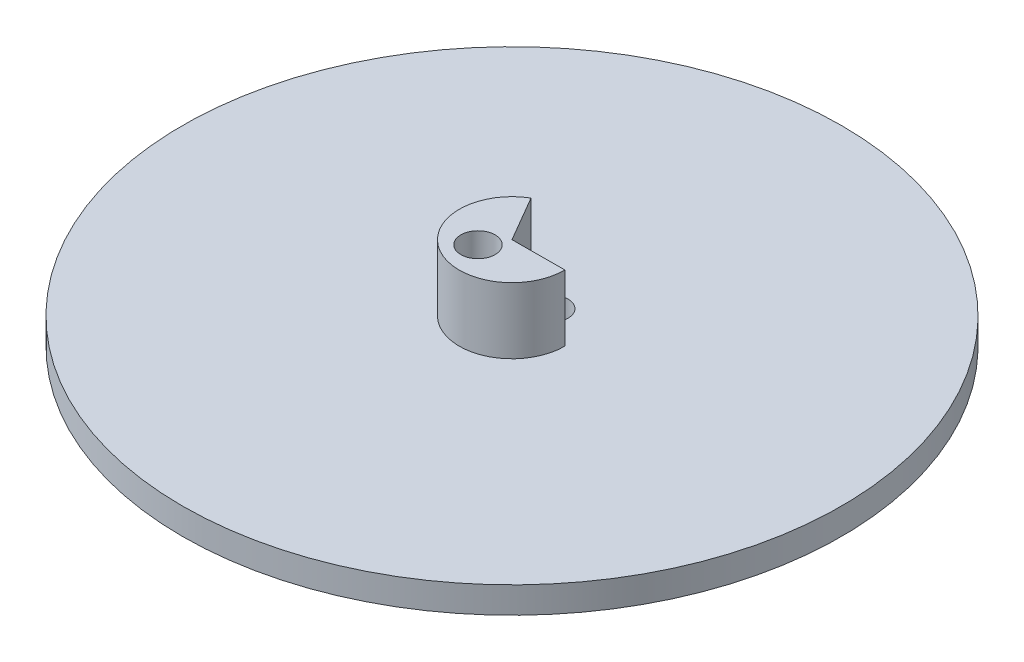
from build123d import *

# Parameters (mm, degrees)
SKETCH1_R           = 63.5
BOSS_EXTRUDE1_DEPTH = 5.08
BOSS_EXTRUDE2_DEPTH = 12.7
SKETCH5_R           = 3.175
CUT_EXTRUDE1_DEPTH  = 6.08
SKETCH6_R           = 3.302
CUT_EXTRUDE2_DEPTH  = 18.78


with BuildPart() as part:
    # Sketch1 → Boss-Extrude1 (new body)
    with BuildSketch(Plane(origin=(0, 0, 0), x_dir=(1, 0, 0), z_dir=(0, 1, 0))):
        Circle(SKETCH1_R)
    extrude(amount=BOSS_EXTRUDE1_DEPTH)

    # Sketch2 → Boss-Extrude2 (add)
    with BuildSketch(Plane(origin=(0, 5.08, 0), x_dir=(1, 0, 0), z_dir=(0, 1, 0))):
        with BuildLine():
            Line((-5.113329796, 8.779490782), (0, 0))
            Line((0, 0), (10.159926948, 0.03852811))
            ThreePointArc((10.159926948, 0.03852811), (-5.046597152, -8.818018893), (-5.113329796, 8.779490782))
        make_face()
    extrude(amount=BOSS_EXTRUDE2_DEPTH)

    # Sketch5 → Cut-Extrude1 (cut, through all)
    with BuildSketch(Plane(origin=(0, 5.08, 0), x_dir=(1, 0, 0), z_dir=(0, 1, 0))):
        with Locations((2.628439651, 5.021053822)):
            Circle(SKETCH5_R)
    extrude(amount=-CUT_EXTRUDE1_DEPTH, mode=Mode.SUBTRACT)

    # Sketch6 → Cut-Extrude2 (cut, through all)
    with BuildSketch(Plane(origin=(0, 17.78, 0), x_dir=(1, 0, 0), z_dir=(0, 1, 0))):
        with Locations((-2.432656569, -4.122340405)):
            Circle(SKETCH6_R)
    extrude(amount=-CUT_EXTRUDE2_DEPTH, mode=Mode.SUBTRACT)


solid = part.part
